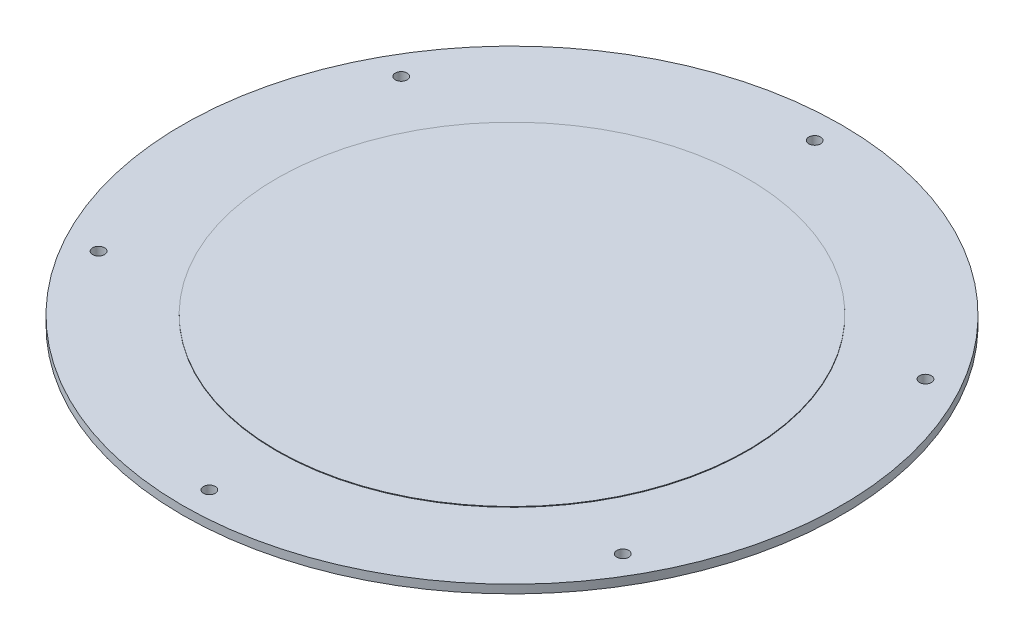
from build123d import *

# Parameters (mm, degrees)
F_8_CLEARANCE_HOLE1_D     = 4.4958
F_8_CLEARANCE_HOLE1_DEPTH = 3.176
CIRPATTERN1_COUNT         = 6
SKETCH4_R                 = 88.9
CUT_EXTRUDE1_DEPTH        = 13.7
BOSS_EXTRUDE2_START       = 0.254
SKETCH5_R                 = 88.9
BOSS_EXTRUDE2_DEPTH       = 2.54


with BuildPart() as part:
    # Sketch1 → Revolve1 (revolve)
    with BuildSketch(Plane(origin=(0, 0, 0), x_dir=(0, 0, -1), z_dir=(1, 0, 0))):
        Polygon((89.535, 0), (92.71, 0), (92.71, 9.525), (124.46, 9.525), (124.46, 12.7), (0, 12.7), (0, 9.525), (89.535, 9.525), align=None)
    revolve(axis=Axis((0, 0, 0), (0, 1, 0)))

    # #8 Clearance Hole1
    with Locations(Plane(origin=(0, 12.7, 0), x_dir=(1, 0, 0), z_dir=(0, 1, 0))):
        with Locations((0, 114.3)):
            f_8_clearance_hole1 = Hole(F_8_CLEARANCE_HOLE1_D / 2, depth=F_8_CLEARANCE_HOLE1_DEPTH)

    # CirPattern1: #8 Clearance Hole1 ×6 about axis
    cirpattern1_axis = Axis((0, 0, 0), (0, 1, 0))
    for i in range(1, CIRPATTERN1_COUNT):
        add(f_8_clearance_hole1.rotate(cirpattern1_axis, i * 360 / CIRPATTERN1_COUNT), mode=Mode.SUBTRACT)

    # Sketch4 → Cut-Extrude1 (cut, through all)
    with BuildSketch(Plane(origin=(0, 12.7, 0), x_dir=(1, 0, 0), z_dir=(0, 1, 0))):
        Circle(SKETCH4_R)
    extrude(amount=-CUT_EXTRUDE1_DEPTH, mode=Mode.SUBTRACT)

    # Sketch5 → Boss-Extrude2 (add)
    with BuildSketch(Plane(origin=(0, 12.7, 0), x_dir=(1, 0, 0), z_dir=(0, 1, 0)).offset(BOSS_EXTRUDE2_START)):
        Circle(SKETCH5_R)
    extrude(amount=-BOSS_EXTRUDE2_DEPTH)


solid = part.part
